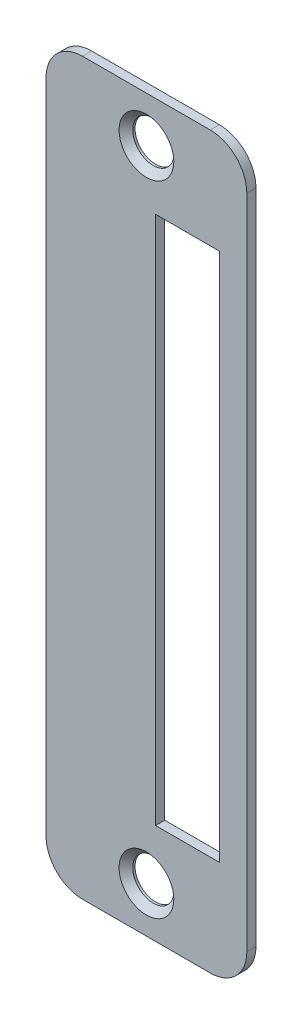
from build123d import *

# Parameters (mm, degrees)
CROQUIS1_R                                  = 2
CROQUIS1_W                                  = 7
CROQUIS1_H                                  = 58
SALIENTE_EXTRUIR1_DEPTH                     = 1
AVELLANADO_PARA_TORNILLO_CON_CABEZA_2_COUNT = 2
AVELLANADO_PARA_TORNILLO_CON_CABEZA_2_PITCH = 70


with BuildPart() as part:
    # Croquis1 → Saliente-Extruir1 (new body)
    with BuildSketch(Plane.XY):
        with BuildLine():
            Line((-11, 36), (-11, -36))
            ThreePointArc((-11, -36), (-9.828427125, -38.828427125), (-7, -40))
            Line((-7, -40), (7, -40))
            ThreePointArc((7, -40), (9.828427125, -38.828427125), (11, -36))
            Line((11, -36), (11, 36))
            ThreePointArc((11, 36), (9.828427125, 38.828427125), (7, 40))
            Line((7, 40), (-7, 40))
            ThreePointArc((-7, 40), (-9.828427125, 38.828427125), (-11, 36))
        make_face()
        with Locations((0, 35)):
            Circle(CROQUIS1_R, mode=Mode.SUBTRACT)
        with Locations((0, -35)):
            Circle(CROQUIS1_R, mode=Mode.SUBTRACT)
        with Locations((4.5, 0)):
            Rectangle(CROQUIS1_W, CROQUIS1_H, mode=Mode.SUBTRACT)
    extrude(amount=SALIENTE_EXTRUIR1_DEPTH)

    # Croquis6 → Avellanado para tornillo con cabeza elevada avellanada de M41 (revolve, cut)
    with BuildSketch(Plane(origin=(0, 35, 1), x_dir=(0, -1, 0), z_dir=(1, 0, 0))):
        Polygon((0, 0), (0, 1), (2.25, 1), (2.25, 0.75), (3, 0), align=None)
    avellanado_para_tornillo_con_cabeza_elev = revolve(axis=Axis((0, 35, 7.35), (0, 0, -1)), mode=Mode.SUBTRACT)

    # Avellanado para tornillo con cabeza  2: Avellanado para tornillo con cabeza elevada avellanada de M41 ×2
    with Locations(*[(0, -i * AVELLANADO_PARA_TORNILLO_CON_CABEZA_2_PITCH, 0) for i in range(1, AVELLANADO_PARA_TORNILLO_CON_CABEZA_2_COUNT)]):
        add(avellanado_para_tornillo_con_cabeza_elev, mode=Mode.SUBTRACT)


solid = part.part
